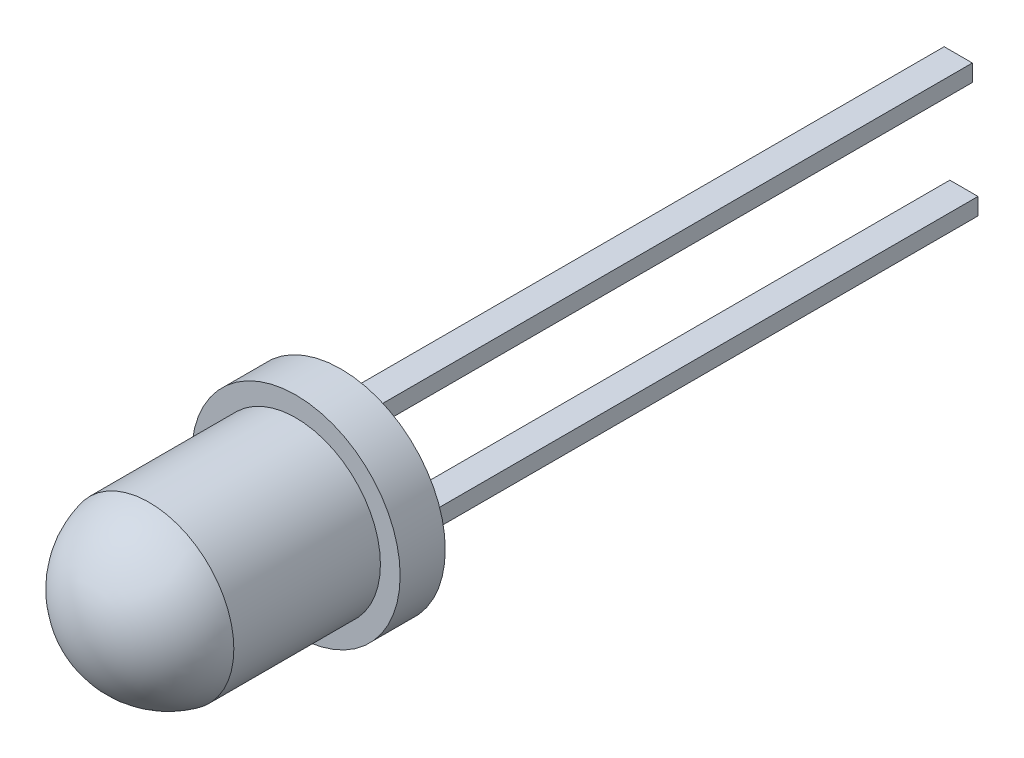
from build123d import *

# Parameters (mm, degrees)
SKETCH1_R           = 1.5
BOSS_EXTRUDE1_DEPTH = 1.3
BOSS_EXTRUDE2_START = -1.3
SKETCH2_R           = 1.85
BOSS_EXTRUDE2_DEPTH = 0.8
DOME1_FACE_RADIUS   = 1.5
DOME1_HEIGHT        = 1.2
BOSS_EXTRUDE3_START = -2.1
SKETCH3_W           = 0.5
SKETCH3_H           = 0.3
BOSS_EXTRUDE3_DEPTH = 12
CUT_EXTRUDE1_START  = -14.1
SKETCH4_W           = 0.5
SKETCH4_H           = 0.3
CUT_EXTRUDE1_DEPTH  = 2


with BuildPart() as part:
    # Sketch1 → Boss-Extrude1 (new body, symmetric)
    with BuildSketch(Plane.XY):
        Circle(SKETCH1_R)
    extrude(amount=BOSS_EXTRUDE1_DEPTH, both=True)

    # Sketch2 → Boss-Extrude2 (add)
    with BuildSketch(Plane.XY.offset(BOSS_EXTRUDE2_START)):
        Circle(SKETCH2_R)
    extrude(amount=-BOSS_EXTRUDE2_DEPTH)

    # Dome1: a dome of height H over a round flat face of radius A is a cap of a sphere of radius (A * A + H * H) / (2 * H)
    dome1_r = (DOME1_FACE_RADIUS * DOME1_FACE_RADIUS + DOME1_HEIGHT * DOME1_HEIGHT) / (2 * DOME1_HEIGHT)
    dome1_base = Plane((0, 0, 1.3), z_dir=(0, 0, 1))
    with Locations(dome1_base.offset(DOME1_HEIGHT - dome1_r)):
        dome1_ball = Sphere(dome1_r, mode=Mode.PRIVATE)
    add(split(dome1_ball, bisect_by=dome1_base, keep=Keep.TOP, mode=Mode.PRIVATE))

    # Sketch3 → Boss-Extrude3 (add)
    with BuildSketch(Plane.XY.offset(BOSS_EXTRUDE3_START)):
        with Locations((1.05, 0)):
            Rectangle(SKETCH3_W, SKETCH3_H)
        with Locations((-1.05, 0)):
            Rectangle(SKETCH3_W, SKETCH3_H)
    extrude(amount=-BOSS_EXTRUDE3_DEPTH)

    # Sketch4 → Cut-Extrude1 (cut)
    with BuildSketch(Plane.XY.offset(CUT_EXTRUDE1_START)):
        with Locations((1.05, 0)):
            Rectangle(SKETCH4_W, SKETCH4_H)
    extrude(amount=CUT_EXTRUDE1_DEPTH, mode=Mode.SUBTRACT)


solid = part.part
